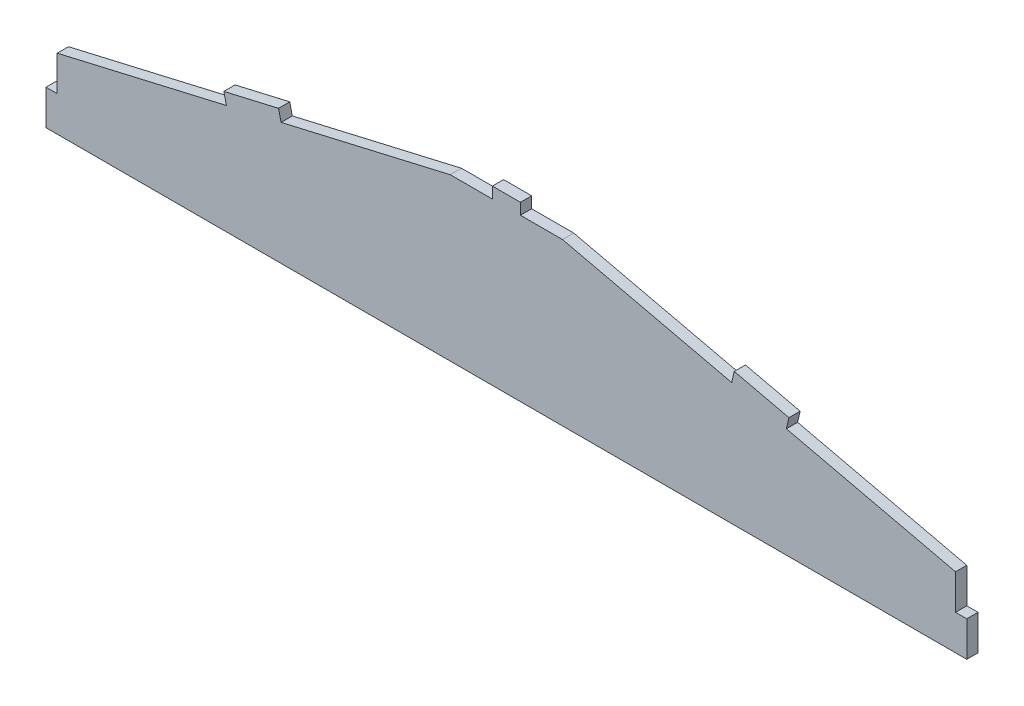
from build123d import *

# Parameters (mm, degrees)
BOSS_EXTRUDE1_DEPTH = 5.08
SKETCH2_W           = 5.08
SKETCH2_H           = 15.875
SKETCH2_W_2         = 12.7
SKETCH2_H_2         = 5.08
BOSS_EXTRUDE2_DEPTH = 5.08


with BuildPart() as part:
    # Sketch1 → Boss-Extrude1 (new body)
    with BuildSketch(Plane.XY):
        Polygon((-203.2, 0), (-203.2, 31.75), (-25.4, 73.025), (0, 73.025), (0, 0), align=None)
    boss_extrude1 = extrude(amount=BOSS_EXTRUDE1_DEPTH)

    # Mirror1: Boss-Extrude1 across plane
    add(boss_extrude1.mirror(Plane(origin=(0, 73.025, 5.08), x_dir=(0, 0, 1), z_dir=(-1, 0, 0))))

    # Sketch2 → Boss-Extrude2 (add)
    with BuildSketch(Plane.XY.offset(5.08)):
        Polygon((-126.671034443, 49.515652719), (-101.928965557, 55.259347281), (-103.077704469, 60.207761059), (-127.819773356, 54.464066496), align=None)
        with Locations((-205.74, 7.9375)):
            Rectangle(SKETCH2_W, SKETCH2_H)
        with Locations((0, 75.565)):
            Rectangle(SKETCH2_W_2, SKETCH2_H_2)
        with Locations((205.74, 7.9375)):
            Rectangle(SKETCH2_W, SKETCH2_H)
        Polygon((126.671034443, 49.515652719), (101.928965557, 55.259347281), (103.077704469, 60.207761059), (127.819773356, 54.464066496), align=None)
    extrude(amount=-BOSS_EXTRUDE2_DEPTH)


solid = part.part
